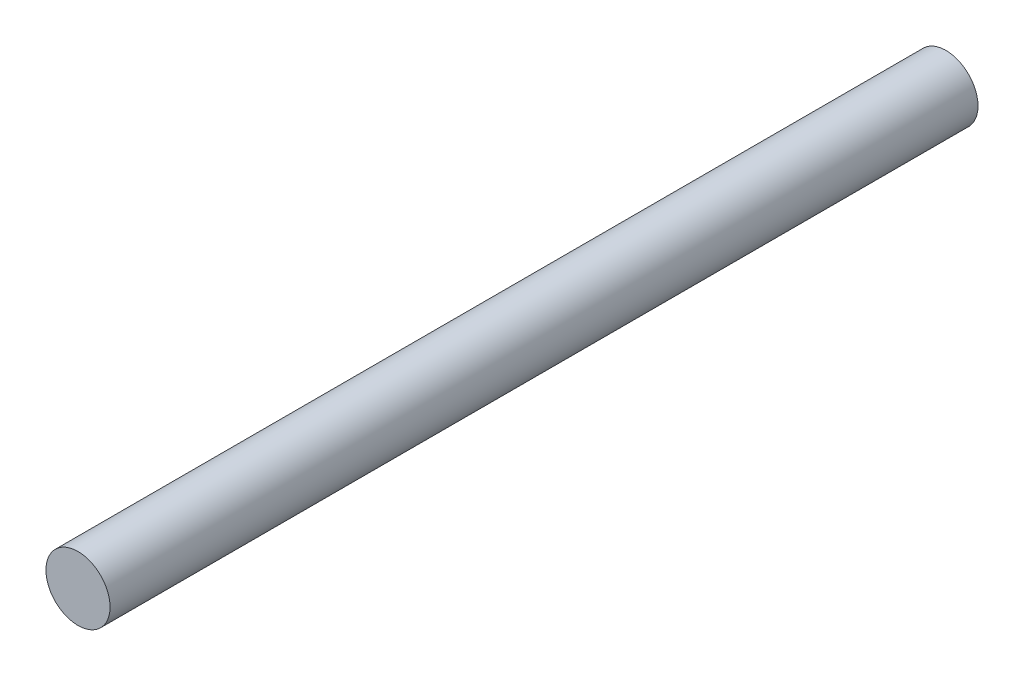
from build123d import *

# Parameters (mm, degrees)
SKETCH1_R           = 5.8
BOSS_EXTRUDE1_DEPTH = 157


with BuildPart() as part:
    # Sketch1 → Boss-Extrude1 (new body)
    with BuildSketch(Plane.XY):
        Circle(SKETCH1_R)
    extrude(amount=BOSS_EXTRUDE1_DEPTH)


solid = part.part
